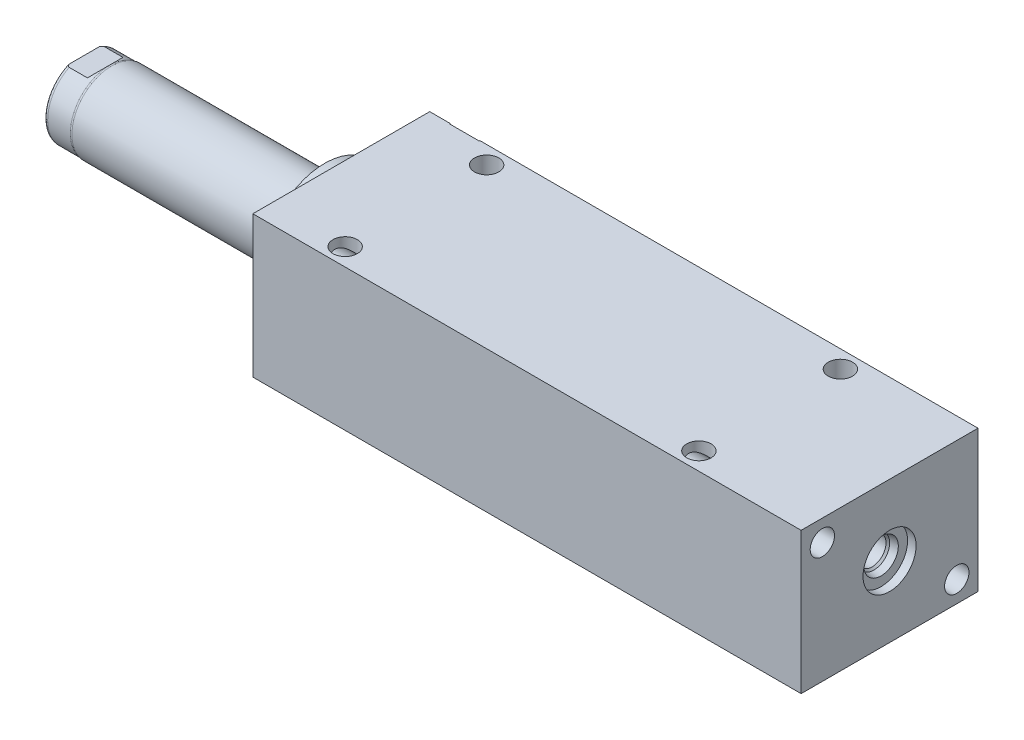
from build123d import *

# Parameters (mm, degrees)
SKETCH1_W          = 63.5
SKETCH1_H          = 50.8
EXTRUDE1_DEPTH     = 196.85
SKETCH5_R          = 22.225
EXTRUDE2_DEPTH     = 5.969
SKETCH6_W          = 14.2875
SKETCH6_H          = 86.36
CUT_EXTRUDE4_DEPTH = 30.48
HOLE1_D            = 8.7376
HOLE1_DEPTH        = 196.85
HOLE2_D            = 8.7376
HOLE2_DEPTH        = 50.8
LPATTERN1_COUNT    = 2
LPATTERN1_PITCH    = 127


with BuildPart() as part:
    # Sketch1 → Extrude1 (new body)
    with BuildSketch(Plane(origin=(0, 0, 0), x_dir=(0, 0, -1), z_dir=(1, 0, 0))):
        Rectangle(SKETCH1_W, SKETCH1_H)
    extrude(amount=EXTRUDE1_DEPTH)

    # S2D0002 → Cut-Revolve1 (revolve, cut)
    with BuildSketch(Plane(origin=(0, 17.4752, 0), x_dir=(-1, 0, 0), z_dir=(0, 1, 0)), mode=Mode.PRIVATE) as cut_revolve1_sk:
        Polygon((-18.8849, -31.496), (-22.225, -31.496), (-22.225, -31.75), (-12.7, -31.75), (-12.7, -17.526), (-17.6784, -17.526), (-17.6784, -28.279393135), (-18.342306865, -28.9433), align=None)
    revolve(cut_revolve1_sk.sketch.rotate(Axis((12.7, 17.4752, -19.13842003), (0, 0, 1)), 180), axis=Axis((12.7, 17.4752, -19.13842003), (0, 0, 1)), mode=Mode.SUBTRACT)  # turned: the seam where the file's is

    # Sketch3 → Cut-Revolve2 (revolve, cut)
    with BuildSketch(Plane(origin=(41.148, 0, -25.146), x_dir=(1, 0, 0), z_dir=(0, 1, 0))):
        Polygon((146.7993, 6.35), (150.1394, 6.35), (150.1394, 6.604), (140.6144, 6.604), (140.6144, -7.62), (145.5928, -7.62), (145.5928, 3.133393135), (146.256706865, 3.7973), align=None)
    revolve(axis=Axis((181.7624, 0, -3.189624441), (0, 0, -1)), mode=Mode.SUBTRACT)

    # Sketch4 → Cut-Revolve3 (revolve, cut)
    with BuildSketch(Plane(origin=(53.975, 0, 0), x_dir=(0, -1, 0), z_dir=(0, 0, 1)), mode=Mode.PRIVATE) as cut_revolve3_sk:
        Polygon((6.1849, 139.827), (9.525, 139.827), (9.525, 142.875), (0, 142.875), (0, 128.4732), (4.9784, 128.4732), (4.9784, 136.610393135), (5.642306865, 137.2743), align=None)
    revolve(cut_revolve3_sk.sketch.rotate(Axis((38.879609832, 0, 0), (1, 0, 0)), 270), axis=Axis((38.879609832, 0, 0), (1, 0, 0)), mode=Mode.SUBTRACT)  # turned: the seam where the file's is

    # Sketch5 → Extrude2 (add)
    with BuildSketch(Plane.ZY):
        Circle(SKETCH5_R)
    extrude(amount=EXTRUDE2_DEPTH)

    # Sketch6 → Revolve1 (revolve)
    with BuildSketch(Plane(origin=(0, 0, 0), x_dir=(0, 0, 1), z_dir=(0, -1, 0)), mode=Mode.PRIVATE) as revolve1_sk:
        with Locations((-7.14375, 49.149)):
            Rectangle(SKETCH6_W, SKETCH6_H)
    revolve(revolve1_sk.sketch.rotate(Axis((5.754582971, 0, 0), (-1, 0, 0)), 180), axis=Axis((5.754582971, 0, 0), (-1, 0, 0)))  # turned: the seam where the file's is

    # S2D0001 → Cut-Revolve4 (revolve, cut)
    with BuildSketch(Plane(origin=(-18.511260017, 3.2639, 0), x_dir=(0, 1, 0), z_dir=(0, 0, 1)), mode=Mode.PRIVATE) as cut_revolve4_sk:
        Polygon((2.286, 71.750017728), (2.286, 57.434739983), (-3.2639, 57.434739983), (-3.2639, 73.817739983), (3.4798, 73.817739983), align=None)
    revolve(cut_revolve4_sk.sketch.rotate(Axis((0, 0, 0), (-1, 0, 0)), 270), axis=Axis((0, 0, 0), (-1, 0, 0)), mode=Mode.SUBTRACT)  # turned: the seam where the file's is

    # Sketch8 → Cut-Revolve5 (revolve, cut)
    with BuildSketch(Plane(origin=(0, 0, 0), x_dir=(0, 0, -1), z_dir=(0, 1, 0)), mode=Mode.PRIVATE) as cut_revolve5_sk:
        with BuildLine():
            Line((-14.2875, 82.423), (-14.097, 83.185))
            Line((-14.097, 83.185), (-14.097, 91.313))
            ThreePointArc((-14.097, 91.313), (-13.996678675, 91.856796865), (-13.708922533, 92.329))
            Line((-13.708922533, 92.329), (-14.2875, 92.329))
            Line((-14.2875, 92.329), (-14.2875, 82.423))
        make_face()
    revolve(cut_revolve5_sk.sketch.rotate(Axis((-12.65936, 0, 0), (-1, 0, 0)), 180), axis=Axis((-12.65936, 0, 0), (-1, 0, 0)), mode=Mode.SUBTRACT)  # turned: the seam where the file's is

    # Sketch12 → Cut-Extrude4 (cut, symmetric)
    with BuildSketch(Plane(origin=(0, 0, 0), x_dir=(0, -1, 0), z_dir=(0, 0, -1))):
        Polygon((12.573, 92.329), (12.573, 84.7598), (14.097, 83.2358), (14.097, 92.329), align=None)
        Polygon((-12.573, 92.329), (-12.573, 84.7598), (-14.097, 83.2358), (-14.097, 92.329), align=None)
    extrude(amount=CUT_EXTRUDE4_DEPTH, both=True, mode=Mode.SUBTRACT)

    # Hole1
    with Locations(Plane.ZY):
        with Locations((-24.13, -17.78), (24.13, 17.78)):
            Hole(HOLE1_D / 2, depth=HOLE1_DEPTH)

    # Hole2
    with Locations(Plane(origin=(0, 25.4, 0), x_dir=(-1, 0, 0), z_dir=(0, 1, 0))):
        with Locations((-26.797, -25.4), (-26.797, 25.4)):
            hole2 = Hole(HOLE2_D / 2, depth=HOLE2_DEPTH)

    # LPattern1: Hole2 ×2
    with Locations(*[(i * LPATTERN1_PITCH, 0, 0) for i in range(1, LPATTERN1_COUNT)]):
        add(hole2, mode=Mode.SUBTRACT)


solid = part.part
